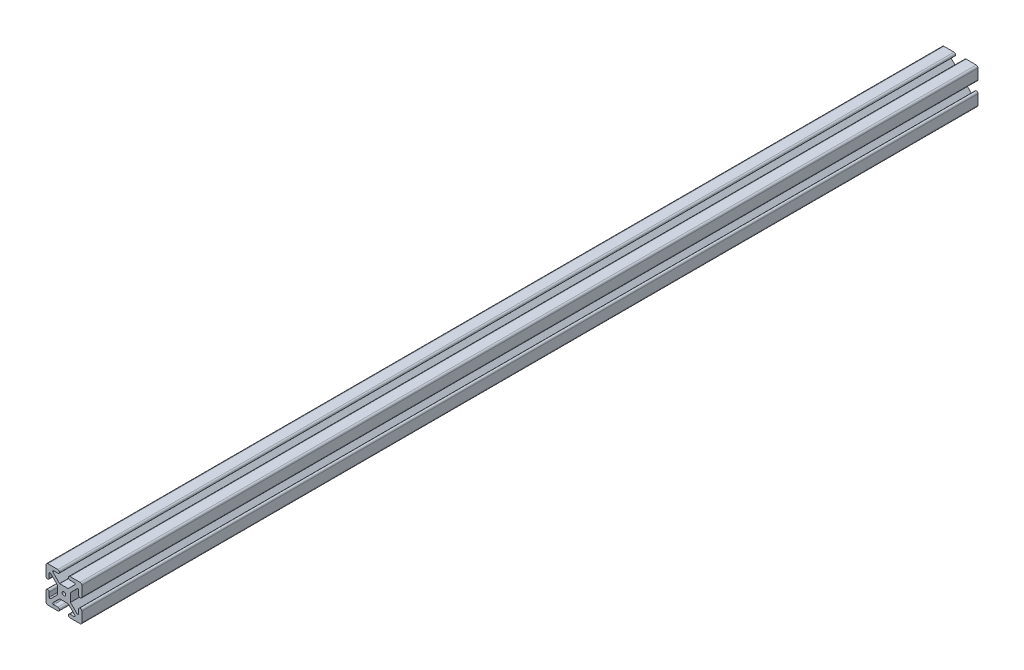
from build123d import *

# Parameters (mm, degrees)
SKETCH1_R           = 1
BOSS_EXTRUDE1_DEPTH = 500


with BuildPart() as part:
    # Sketch1 → Boss-Extrude1 (new body)
    with BuildSketch(Plane.XY.offset(50)):
        with BuildLine():
            Line((-10, 9), (-10, 3.4))
            ThreePointArc((-10, 3.4), (-9.1, 2.5), (-8.2, 3.4))
            Line((-8.2, 3.4), (-8.2, 5.75))
            ThreePointArc((-8.2, 5.75), (-7.891341716, 6.211939766), (-7.346446609, 6.103553391))
            Line((-7.346446609, 6.103553391), (-3.656030738, 2.384202014))
            ThreePointArc((-3.656030738, 2.384202014), (-3.651519225, 2.367364818), (-3.65, 2.35))
            Line((-3.65, 2.35), (-3.65, -2.35))
            ThreePointArc((-3.65, -2.35), (-3.651519225, -2.367364818), (-3.656030738, -2.384202014))
            Line((-3.656030738, -2.384202014), (-7.346446609, -6.103553391))
            ThreePointArc((-7.346446609, -6.103553391), (-7.891341716, -6.211939766), (-8.2, -5.75))
            Line((-8.2, -5.75), (-8.2, -3.4))
            ThreePointArc((-8.2, -3.4), (-9.1, -2.5), (-10, -3.4))
            Line((-10, -3.4), (-10, -9))
            ThreePointArc((-10, -9), (-9.707106781, -9.707106781), (-9, -10))
            Line((-9, -10), (-3.4, -10))
            ThreePointArc((-3.4, -10), (-2.5, -9.1), (-3.4, -8.2))
            Line((-3.4, -8.2), (-5.75, -8.2))
            ThreePointArc((-5.75, -8.2), (-6.211939766, -7.891341716), (-6.103553391, -7.346446609))
            Line((-6.103553391, -7.346446609), (-2.443969262, -3.715797986))
            ThreePointArc((-2.443969262, -3.715797986), (-2.407357644, -3.668084796), (-2.35, -3.65))
            Line((-2.35, -3.65), (2.35, -3.65))
            ThreePointArc((2.35, -3.65), (2.407357644, -3.668084796), (2.443969262, -3.715797986))
            Line((2.443969262, -3.715797986), (6.103553391, -7.346446609))
            ThreePointArc((6.103553391, -7.346446609), (6.211939766, -7.891341716), (5.75, -8.2))
            Line((5.75, -8.2), (3.4, -8.2))
            ThreePointArc((3.4, -8.2), (2.5, -9.1), (3.4, -10))
            Line((3.4, -10), (9, -10))
            ThreePointArc((9, -10), (9.707106781, -9.707106781), (10, -9))
            Line((10, -9), (10, -3.4))
            ThreePointArc((10, -3.4), (9.1, -2.5), (8.2, -3.4))
            Line((8.2, -3.4), (8.2, -5.75))
            ThreePointArc((8.2, -5.75), (7.891341716, -6.211939766), (7.346446609, -6.103553391))
            Line((7.346446609, -6.103553391), (3.656030738, -2.384202014))
            ThreePointArc((3.656030738, -2.384202014), (3.651519225, -2.367364818), (3.65, -2.35))
            Line((3.65, -2.35), (3.65, 2.35))
            ThreePointArc((3.65, 2.35), (3.651519225, 2.367364818), (3.656030738, 2.384202014))
            Line((3.656030738, 2.384202014), (7.346446609, 6.103553391))
            ThreePointArc((7.346446609, 6.103553391), (7.891341716, 6.211939766), (8.2, 5.75))
            Line((8.2, 5.75), (8.2, 3.4))
            ThreePointArc((8.2, 3.4), (9.1, 2.5), (10, 3.4))
            Line((10, 3.4), (10, 9))
            ThreePointArc((10, 9), (9.707106781, 9.707106781), (9, 10))
            Line((9, 10), (3.4, 10))
            ThreePointArc((3.4, 10), (2.5, 9.1), (3.4, 8.2))
            Line((3.4, 8.2), (5.75, 8.2))
            ThreePointArc((5.75, 8.2), (6.211939766, 7.891341716), (6.103553391, 7.346446609))
            Line((6.103553391, 7.346446609), (2.443969262, 3.715797986))
            ThreePointArc((2.443969262, 3.715797986), (2.407357644, 3.668084796), (2.35, 3.65))
            Line((2.35, 3.65), (-2.35, 3.65))
            ThreePointArc((-2.35, 3.65), (-2.407357644, 3.668084796), (-2.443969262, 3.715797986))
            Line((-2.443969262, 3.715797986), (-6.103553391, 7.346446609))
            ThreePointArc((-6.103553391, 7.346446609), (-6.211939766, 7.891341716), (-5.75, 8.2))
            Line((-5.75, 8.2), (-3.4, 8.2))
            ThreePointArc((-3.4, 8.2), (-2.5, 9.1), (-3.4, 10))
            Line((-3.4, 10), (-9, 10))
            ThreePointArc((-9, 10), (-9.707106781, 9.707106781), (-10, 9))
        make_face()
        Circle(SKETCH1_R, mode=Mode.SUBTRACT)
    extrude(amount=-BOSS_EXTRUDE1_DEPTH)


solid = part.part
